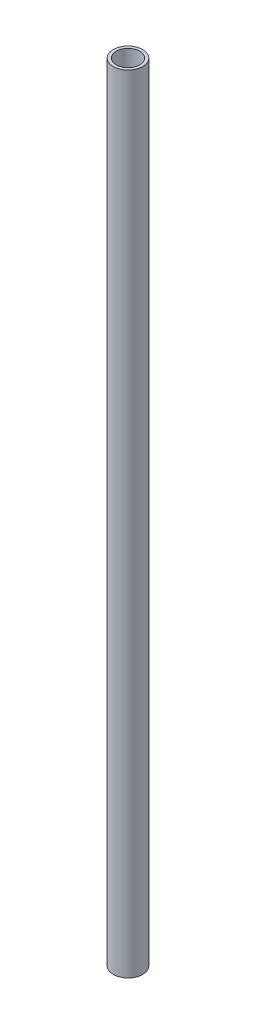
from build123d import *

# Parameters (mm, degrees)
SKETCH1_R           = 4.7625
SKETCH1_R_2         = 3.81
BOSS_EXTRUDE1_DEPTH = 254


with BuildPart() as part:
    # Sketch1 → Boss-Extrude1 (new body)
    with BuildSketch(Plane(origin=(0, 0, 0), x_dir=(1, 0, 0), z_dir=(0, 1, 0))):
        Circle(SKETCH1_R)
        Circle(SKETCH1_R_2, mode=Mode.SUBTRACT)
    extrude(amount=BOSS_EXTRUDE1_DEPTH)


solid = part.part
